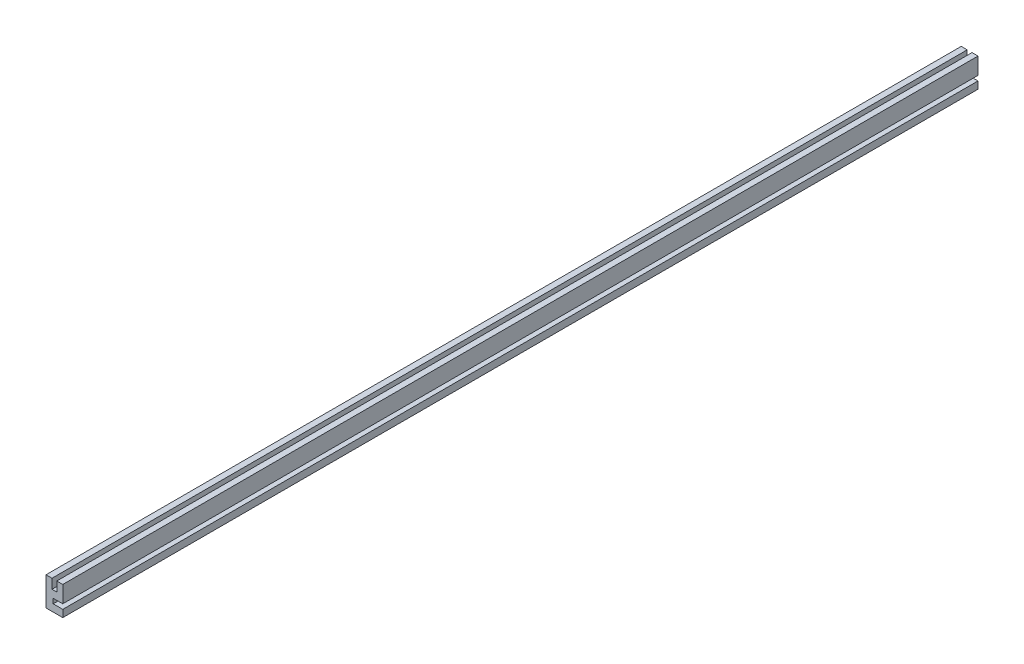
from build123d import *

# Parameters (mm, degrees)
SKETCH1_W                            = 11.1125
SKETCH1_H                            = 19.05
WOOD_STRIP_DEPTH                     = 303.2125
SKETCH2_W                            = 3.175
SKETCH2_H                            = 6.35
SLOT_FOR_MOUNTING_TO_EXTRUSION_DEPTH = 607.425
SKETCH3_W                            = 6.35
SKETCH3_H                            = 3.175
SLOT_FOR_DIFFUSER_DEPTH              = 607.425


with BuildPart() as part:
    # Sketch1 → Wood Strip (new body, symmetric)
    with BuildSketch(Plane.XY):
        Rectangle(SKETCH1_W, SKETCH1_H)
    extrude(amount=WOOD_STRIP_DEPTH, both=True)

    # Sketch2 → Slot for Mounting to Extrusion (cut, through all)
    with BuildSketch(Plane.XY.offset(303.2125)):
        with Locations((0, 6.35)):
            Rectangle(SKETCH2_W, SKETCH2_H)
    extrude(amount=-SLOT_FOR_MOUNTING_TO_EXTRUSION_DEPTH, mode=Mode.SUBTRACT)

    # Sketch3 → Slot for Diffuser (cut, through all)
    with BuildSketch(Plane.XY.offset(303.2125)):
        with Locations((2.38125, -3.175)):
            Rectangle(SKETCH3_W, SKETCH3_H)
    extrude(amount=-SLOT_FOR_DIFFUSER_DEPTH, mode=Mode.SUBTRACT)


solid = part.part
